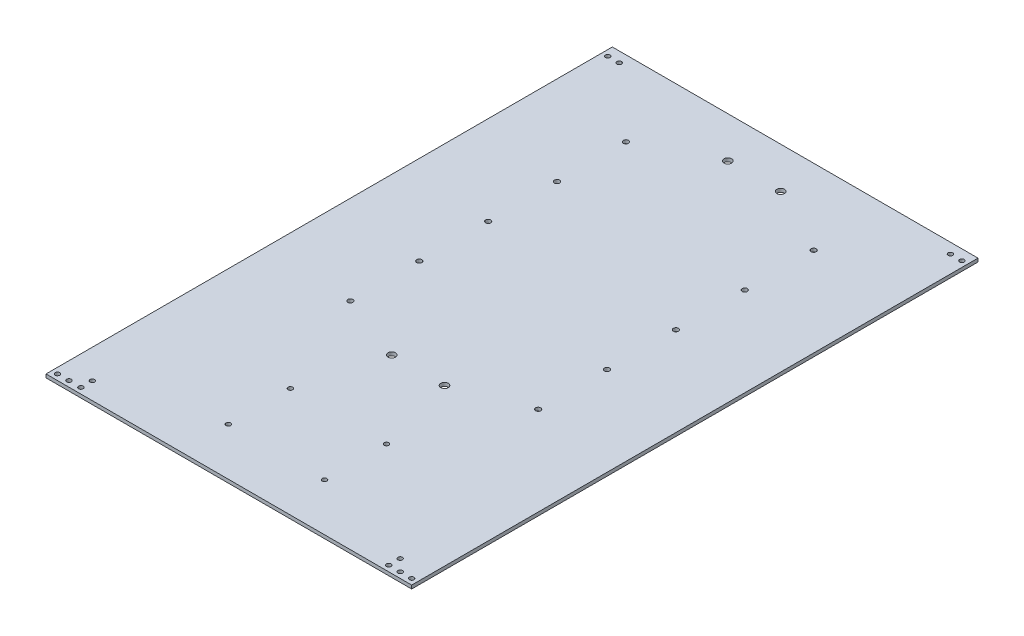
from build123d import *

# Parameters (mm, degrees)
SKETCH_1_W               = 318.56
SKETCH_1_H               = 493.33
SKETCH_1_R               = 2.25
SKETCH_1_R_2             = 2
EXTRUDE_1_DEPTH          = 3
SKETCH_2_R               = 2
SKETCH_2_R_2             = 3.3
CUT_EXTRUDE_1_DEPTH      = 1
CUT_EXTRUDE_1_DEPTH_BACK = 4


with BuildPart() as part:
    # 草图1 → 凸台-拉伸1 (new body)
    with BuildSketch(Plane(origin=(0, 0, 0), x_dir=(1, 0, 0), z_dir=(0, 1, 0))):
        Rectangle(SKETCH_1_W, SKETCH_1_H)
        with Locations((81.78, 181.012789491)):
            Circle(SKETCH_1_R, mode=Mode.SUBTRACT)
        with Locations((81.78, 121.012789491)):
            Circle(SKETCH_1_R, mode=Mode.SUBTRACT)
        with Locations((81.78, 61.012789491)):
            Circle(SKETCH_1_R, mode=Mode.SUBTRACT)
        with Locations((81.78, -58.987210509)):
            Circle(SKETCH_1_R, mode=Mode.SUBTRACT)
        with Locations((81.78, 1.012789491)):
            Circle(SKETCH_1_R, mode=Mode.SUBTRACT)
        with Locations((-81.78, -58.987210509)):
            Circle(SKETCH_1_R, mode=Mode.SUBTRACT)
        with Locations((-81.78, 1.012789491)):
            Circle(SKETCH_1_R, mode=Mode.SUBTRACT)
        with Locations((-81.78, 61.012789491)):
            Circle(SKETCH_1_R, mode=Mode.SUBTRACT)
        with Locations((-81.78, 121.012789491)):
            Circle(SKETCH_1_R, mode=Mode.SUBTRACT)
        with Locations((-81.78, 181.012789491)):
            Circle(SKETCH_1_R, mode=Mode.SUBTRACT)
        with Locations((-154.28, 237.665)):
            Circle(SKETCH_1_R_2, mode=Mode.SUBTRACT)
        with Locations((-144.28, 237.665)):
            Circle(SKETCH_1_R_2, mode=Mode.SUBTRACT)
        with Locations((144.28, 237.665)):
            Circle(SKETCH_1_R_2, mode=Mode.SUBTRACT)
        with Locations((154.28, 237.665)):
            Circle(SKETCH_1_R_2, mode=Mode.SUBTRACT)
        with Locations((134.28, -231.665)):
            Circle(SKETCH_1_R_2, mode=Mode.SUBTRACT)
        with Locations((134.28, -241.665)):
            Circle(SKETCH_1_R_2, mode=Mode.SUBTRACT)
        with Locations((144.28, -241.665)):
            Circle(SKETCH_1_R_2, mode=Mode.SUBTRACT)
        with Locations((154.28, -241.665)):
            Circle(SKETCH_1_R_2, mode=Mode.SUBTRACT)
        with Locations((-133.885842783, -231.665)):
            Circle(SKETCH_1_R_2, mode=Mode.SUBTRACT)
        with Locations((-133.885842783, -241.665)):
            Circle(SKETCH_1_R_2, mode=Mode.SUBTRACT)
        with Locations((-144.28, -241.665)):
            Circle(SKETCH_1_R_2, mode=Mode.SUBTRACT)
        with Locations((-154.28, -241.665)):
            Circle(SKETCH_1_R_2, mode=Mode.SUBTRACT)
    extrude(amount=EXTRUDE_1_DEPTH)

    # 草图2 → 切除-拉伸1 (cut, two sides)
    with BuildSketch(Plane.XZ) as cut_extrude_1_sk:
        with Locations((41.9, 205.217949373)):
            Circle(SKETCH_2_R)
        with Locations((-41.9, 151.217949373)):
            Circle(SKETCH_2_R)
        with Locations((41.9, 151.217949373)):
            Circle(SKETCH_2_R)
        with Locations((-41.9, 205.217949373)):
            Circle(SKETCH_2_R)
        with Locations((-23, -211.012789491)):
            Circle(SKETCH_2_R_2)
        with Locations((23, -211.012789491)):
            Circle(SKETCH_2_R_2)
        with Locations((-23, 81.776091935)):
            Circle(SKETCH_2_R_2)
        with Locations((23, 81.776091935)):
            Circle(SKETCH_2_R_2)
    extrude(amount=CUT_EXTRUDE_1_DEPTH, mode=Mode.SUBTRACT)
    extrude(cut_extrude_1_sk.sketch, amount=-CUT_EXTRUDE_1_DEPTH_BACK, mode=Mode.SUBTRACT)


solid = part.part
